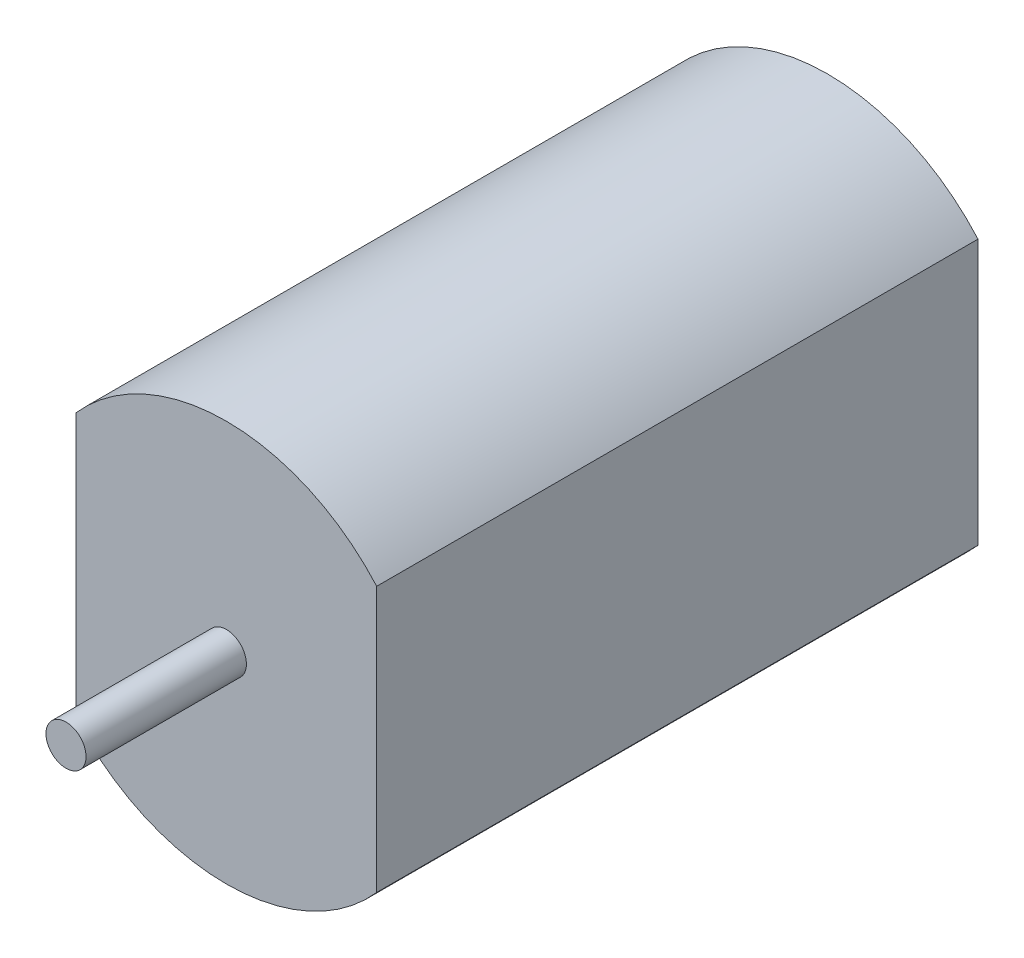
from build123d import *

# Parameters (mm, degrees)
SKETCH_1_R          = 10
EXTRUDE_1_DEPTH     = 30
CUT_EXTRUDE_1_DEPTH = 30
SKETCH_3_R          = 1
EXTRUDE_2_DEPTH     = 8


with BuildPart() as part:
    # 草图1 → 凸台-拉伸1 (new body)
    with BuildSketch(Plane.XY):
        Circle(SKETCH_1_R)
    extrude(amount=EXTRUDE_1_DEPTH)

    # 草图2 → 切除-拉伸1 (cut)
    with BuildSketch(Plane.XY.offset(30)):
        with BuildLine():
            ThreePointArc((10, 0), (9.354143467, 3.535533906), (7.5, 6.614378278))
            Line((7.5, 6.614378278), (7.5, -6.614378278))
            ThreePointArc((7.5, -6.614378278), (9.354143467, -3.535533906), (10, 0))
        make_face()
        with BuildLine():
            Line((-7.5, -6.614378278), (-7.5, 6.614378278))
            ThreePointArc((-7.5, 6.614378278), (-10, 0), (-7.5, -6.614378278))
        make_face()
    extrude(amount=-CUT_EXTRUDE_1_DEPTH, mode=Mode.SUBTRACT)

    # 草图3 → 凸台-拉伸2 (add)
    with BuildSketch(Plane.XY.offset(30)):
        Circle(SKETCH_3_R)
    extrude(amount=EXTRUDE_2_DEPTH)


solid = part.part
